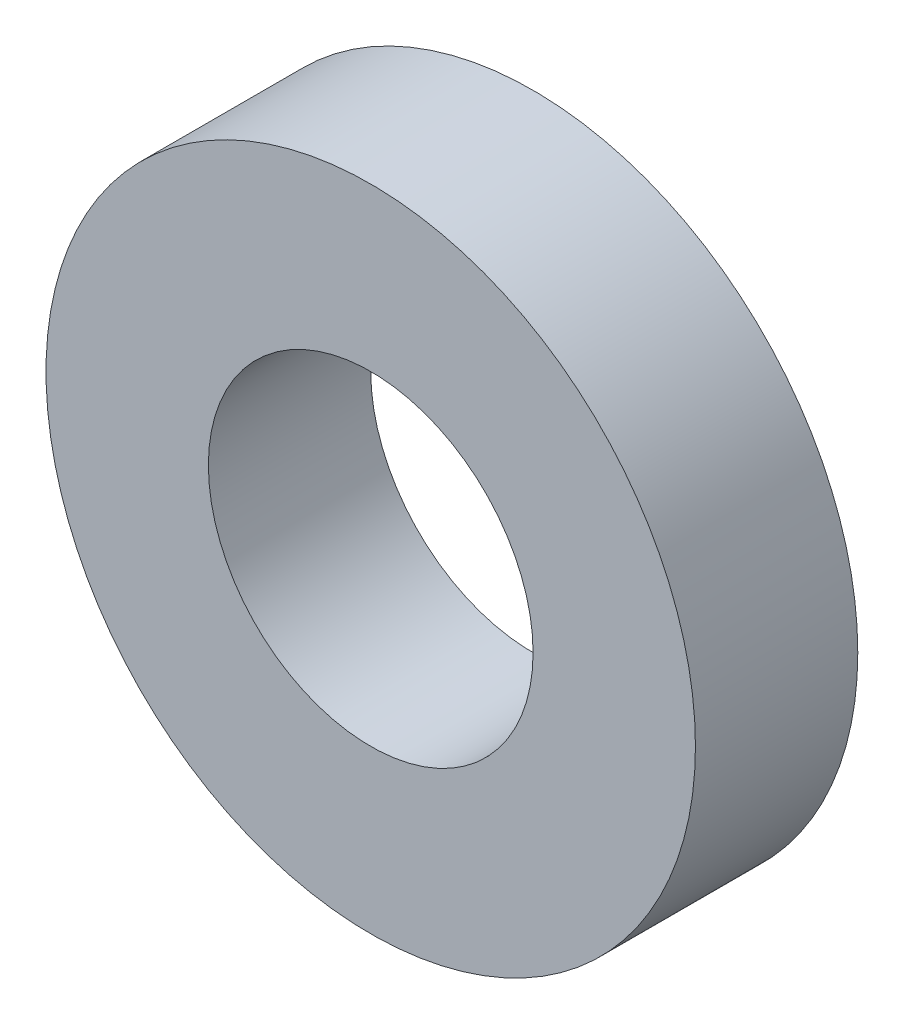
from build123d import *

# Parameters (mm, degrees)
SKETCH1_R           = 6.35
SKETCH1_R_2         = 3.175
BOSS_EXTRUDE1_DEPTH = 3.175


with BuildPart() as part:
    # Sketch1 → Boss-Extrude1 (new body)
    with BuildSketch(Plane.XY):
        Circle(SKETCH1_R)
        Circle(SKETCH1_R_2, mode=Mode.SUBTRACT)
    extrude(amount=BOSS_EXTRUDE1_DEPTH)


solid = part.part
